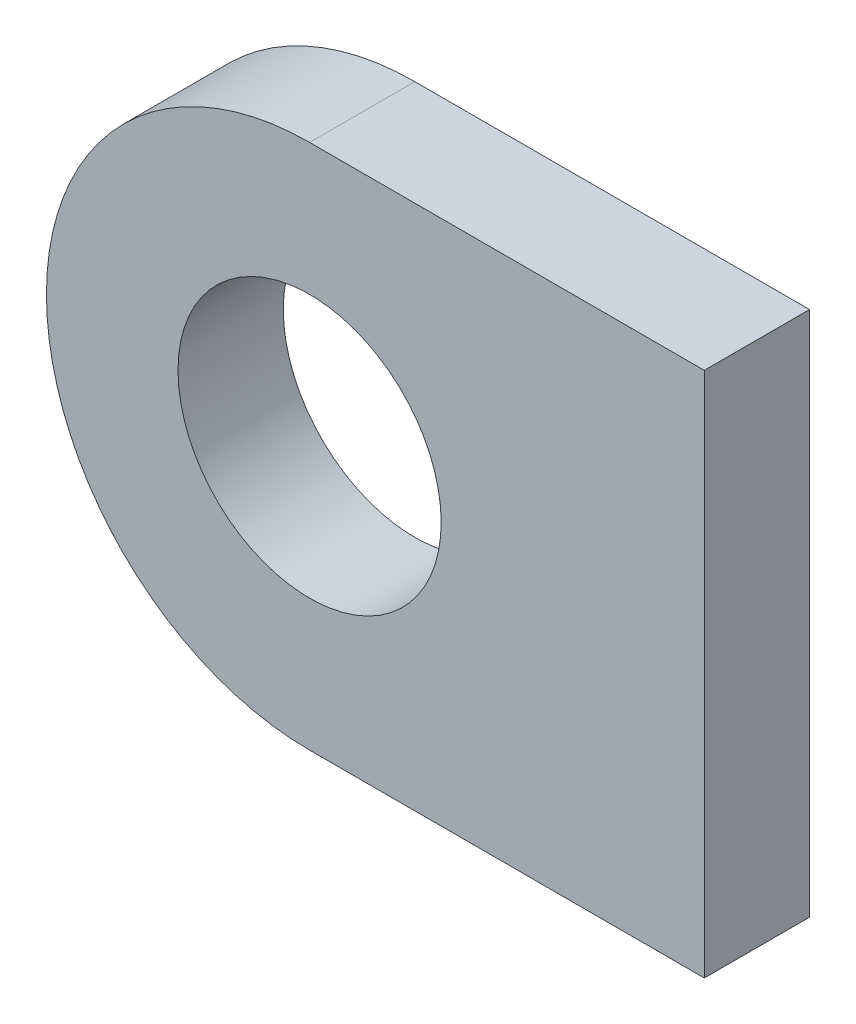
from build123d import *

# Parameters (mm, degrees)
SKETCH_1_R      = 10
SKETCH_1_R_2    = 5
EXTRUDE_1_DEPTH = 4


with BuildPart() as part:
    # Эскиз1 → Бобышка-Вытянуть1 (new body)
    with BuildSketch(Plane.XY):
        Circle(SKETCH_1_R)
        Circle(SKETCH_1_R_2, mode=Mode.SUBTRACT)
        with BuildLine():
            Line((15, 10), (0, 10))
            ThreePointArc((0, 10), (7.071067812, 7.071067812), (10, 0))
            ThreePointArc((10, 0), (7.071067812, -7.071067812), (0, -10))
            Line((0, -10), (15, -10))
            Line((15, -10), (15, 10))
        make_face()
    extrude(amount=EXTRUDE_1_DEPTH)


solid = part.part
